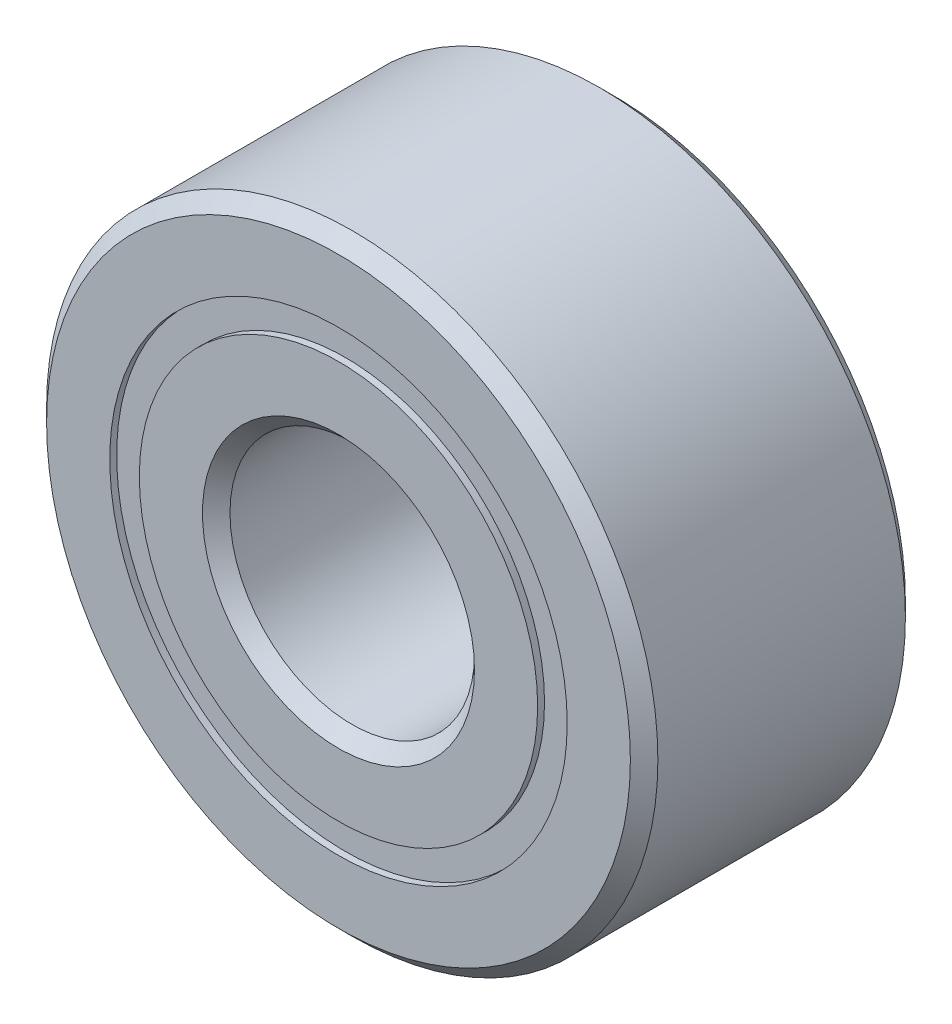
from build123d import *

# Parameters (mm, degrees)
CIRPATTERN1_COUNT = 10
SKETCH5_W         = 0.879852806
SKETCH5_H         = 0.383847032


with BuildPart() as part:
    # Sketch1 → Revolve1 (revolve)
    with BuildSketch(Plane(origin=(0, 0, 0), x_dir=(0, 0, -1), z_dir=(1, 0, 0))):
        with BuildLine():
            Line((1.607058, 3.96875), (-1.607058, 3.96875))
            Line((-1.607058, 3.96875), (-1.78562, 3.790188))
            Line((-1.78562, 3.790188), (-1.78562, 2.970048516))
            Line((-1.78562, 2.970048516), (-0.793608889, 2.970048516))
            ThreePointArc((-0.793608889, 2.970048516), (0, 3.594611194), (0.793608889, 2.970048516))
            Line((0.793608889, 2.970048516), (1.78562, 2.970048516))
            Line((1.78562, 2.970048516), (1.78562, 3.790188))
            Line((1.78562, 3.790188), (1.607058, 3.96875))
        make_face()
    revolve(axis=Axis((0, 0, 1.78562), (0, 0, -1)))


with BuildPart() as body_2:
    # Sketch3 → Revolve3 (revolve)
    with BuildSketch(Plane(origin=(0, 0, 0), x_dir=(0, 0, -1), z_dir=(1, 0, 0))):
        with BuildLine():
            Line((-0.793608889, 2.586201484), (-1.78562, 2.586201484))
            Line((-1.78562, 2.586201484), (-1.78562, 1.766062))
            Line((-1.78562, 1.766062), (-1.607058, 1.5875))
            Line((-1.607058, 1.5875), (1.607058, 1.5875))
            Line((1.607058, 1.5875), (1.78562, 1.766062))
            Line((1.78562, 1.766062), (1.78562, 2.586201484))
            Line((1.78562, 2.586201484), (0.793608889, 2.586201484))
            ThreePointArc((0.793608889, 2.586201484), (0, 1.961638806), (-0.793608889, 2.586201484))
        make_face()
    revolve(axis=Axis((0, 0, 1.78562), (0, 0, -1)))


with BuildPart() as body_3:
    # Sketch4 → Revolve4 (revolve)
    with BuildSketch(Plane(origin=(0, 0, 0), x_dir=(0, 0, -1), z_dir=(1, 0, 0))):
        with BuildLine():
            Line((-0.816486194, 2.778125), (0.816486194, 2.778125))
            ThreePointArc((0.816486194, 2.778125), (0, 3.594611194), (-0.816486194, 2.778125))
        make_face()
    revolve(axis=Axis((0, 2.778125, 0.816486194), (0, 0, -1)))


with BuildPart() as cirpattern1_1:
    # CirPattern1: pattern copy
    add(body_3.part.rotate(Axis((0, 0, -1.78562), (0, 0, 1)), 1 * 360 / CIRPATTERN1_COUNT))


with BuildPart() as cirpattern1_2:
    # CirPattern1: pattern copy
    add(body_3.part.rotate(Axis((0, 0, -1.78562), (0, 0, 1)), 2 * 360 / CIRPATTERN1_COUNT))


with BuildPart() as cirpattern1_3:
    # CirPattern1: pattern copy
    add(body_3.part.rotate(Axis((0, 0, -1.78562), (0, 0, 1)), 3 * 360 / CIRPATTERN1_COUNT))


with BuildPart() as cirpattern1_4:
    # CirPattern1: pattern copy
    add(body_3.part.rotate(Axis((0, 0, -1.78562), (0, 0, 1)), 4 * 360 / CIRPATTERN1_COUNT))


with BuildPart() as cirpattern1_5:
    # CirPattern1: pattern copy
    add(body_3.part.rotate(Axis((0, 0, -1.78562), (0, 0, 1)), 5 * 360 / CIRPATTERN1_COUNT))


with BuildPart() as cirpattern1_6:
    # CirPattern1: pattern copy
    add(body_3.part.rotate(Axis((0, 0, -1.78562), (0, 0, 1)), 6 * 360 / CIRPATTERN1_COUNT))


with BuildPart() as cirpattern1_7:
    # CirPattern1: pattern copy
    add(body_3.part.rotate(Axis((0, 0, -1.78562), (0, 0, 1)), 7 * 360 / CIRPATTERN1_COUNT))


with BuildPart() as cirpattern1_8:
    # CirPattern1: pattern copy
    add(body_3.part.rotate(Axis((0, 0, -1.78562), (0, 0, 1)), 8 * 360 / CIRPATTERN1_COUNT))


with BuildPart() as cirpattern1_9:
    # CirPattern1: pattern copy
    add(body_3.part.rotate(Axis((0, 0, -1.78562), (0, 0, 1)), 9 * 360 / CIRPATTERN1_COUNT))


with BuildPart() as body_13:
    # Sketch5 → Revolve5 (revolve)
    with BuildSketch(Plane(origin=(0, 0, 0), x_dir=(0, 0, -1), z_dir=(1, 0, 0))):
        with Locations((-1.256412597, 2.778125)):
            Rectangle(SKETCH5_W, SKETCH5_H)
        with Locations((1.256412597, 2.778125)):
            Rectangle(SKETCH5_W, SKETCH5_H)
    revolve(axis=Axis((0, 0, 1.78562), (0, 0, -1)))


solid = Compound([part.part, body_2.part, body_3.part, cirpattern1_1.part, cirpattern1_2.part, cirpattern1_3.part, cirpattern1_4.part, cirpattern1_5.part, cirpattern1_6.part, cirpattern1_7.part, cirpattern1_8.part, cirpattern1_9.part, body_13.part])
